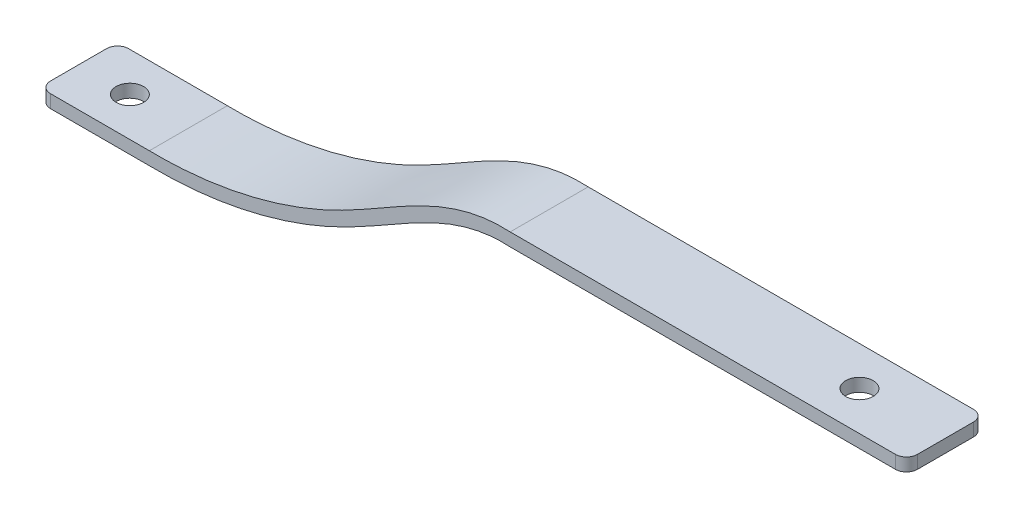
from build123d import *

# Parameters (mm, degrees)
BOSS_EXTRUDE1_DEPTH     = 18
SKETCH2_R               = 3.175
CUT_EXTRUDE1_DEPTH      = 1.048172096
CUT_EXTRUDE1_DEPTH_BACK = 29.412494693
FILLET1_R               = 2.54


with BuildPart() as part:
    # Sketch1 → Boss-Extrude1 (new body)
    with BuildSketch(Plane.XY):
        with BuildLine():
            Line((0, -26.9), (25.314659544, -26.9))
            add(Edge.make_bspline(
                [(25.314659544, -26.9), (29.018808902, -26.95946599), (36.438320652, -26.653818936), (47.452273732, -24.92488313), (58.262486614, -21.924318782), (67.016013602, -18.37965694), (73.811742851, -14.890308818), (80.427413207, -11.130302547), (86.897235914, -7.369109823), (93.386399422, -4.327041649), (98.298472606, -2.578666278), (102.47088341, -1.703494583), (105.870866673, -1.428331861), (107.623577227, -1.449984583), (108.491279544, -1.5)],
                knots=[0.000136912, 0.000136912, 0.000136912, 0.000136912, 0.125180551, 0.250224189, 0.375267828, 0.500311467, 0.562833286, 0.625355105, 0.750398744, 0.812920563, 0.875442382, 0.937964202, 0.969225111, 1.000486021, 1.000486021, 1.000486021, 1.000486021], degree=3))
            Line((108.491279544, -1.5), (200, -1.5))
            Line((200, -1.5), (200, 1.5))
            Line((200, 1.5), (108.577128094, 1.5))
            add(Edge.make_bspline(
                [(25.338879667, -23.9), (28.926162088, -23.958039606), (36.111765907, -23.664827946), (46.778323763, -21.99406658), (57.248447209, -19.093410872), (65.732493814, -15.662477543), (72.314760278, -12.28848554), (78.848846724, -8.579093587), (85.394977085, -4.766737379), (92.155894885, -1.585137398), (97.388130608, 0.290112445), (101.932358434, 1.257689935), (105.679869219, 1.570192395), (107.61823033, 1.553901023), (108.577128094, 1.5)],
                knots=[-0.00013852, -0.00013852, -0.00013852, -0.00013852, 0.124820277, 0.249779073, 0.37473787, 0.499696666, 0.562176065, 0.624655463, 0.749614259, 0.812093658, 0.874573056, 0.937052454, 0.968292153, 0.999531852, 0.999531852, 0.999531852, 0.999531852], degree=3))
            Line((25.338879667, -23.9), (0, -23.9))
            Line((0, -23.9), (0, -26.9))
        make_face()
    extrude(amount=BOSS_EXTRUDE1_DEPTH)

    # Sketch2 → Cut-Extrude1 (cut, two sides)
    with BuildSketch(Plane(origin=(0, 1.5, 0), x_dir=(1, 0, 0), z_dir=(0, 1, 0))) as cut_extrude1_sk:
        with Locations((11.847374462, -9)):
            Circle(SKETCH2_R)
        with Locations((180.157387408, -9)):
            Circle(SKETCH2_R)
    extrude(amount=CUT_EXTRUDE1_DEPTH, mode=Mode.SUBTRACT)
    extrude(cut_extrude1_sk.sketch, amount=-CUT_EXTRUDE1_DEPTH_BACK, mode=Mode.SUBTRACT)

    # Fillet1
    fillet1_edges = [part.edges().sort_by_distance(p)[0] for p in [
        (0, -25.4, 0),
        (200, 0, 18),
        (0, -25.4, 18),
        (200, 0, 0),
    ]]
    fillet(fillet1_edges, radius=FILLET1_R)


solid = part.part
